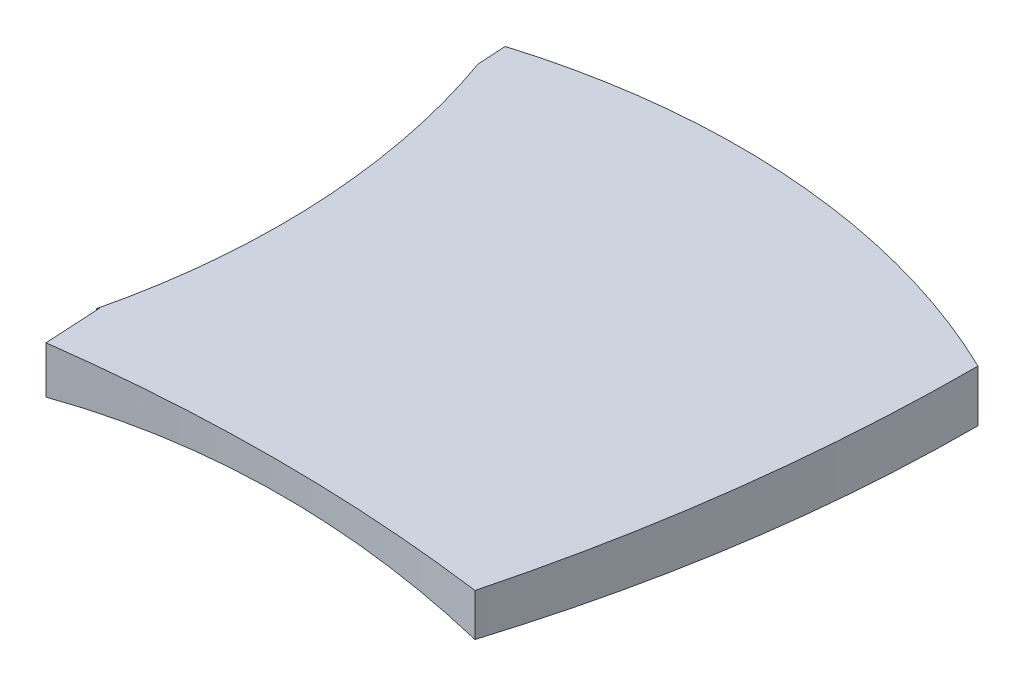
from build123d import *

# Parameters (mm, degrees)
BOSS_EXTRUDE1_DEPTH     = 15
CUT_EXTRUDE2_DEPTH      = 58
CUT_EXTRUDE2_DEPTH_BACK = 63


with BuildPart() as part:
    # Sketch1 → Boss-Extrude1 (new body)
    with BuildSketch(Plane(origin=(0, 0, 0), x_dir=(1, 0, 0), z_dir=(0, 1, 0))):
        with BuildLine():
            Line((-40, -45), (-40.554700196, -35.015396468))
            Line((-40.554700196, -35.015396468), (-40.751707535, -35.387312812))
            ThreePointArc((-40.751707535, -35.387312812), (-37.497275944, 0.081671518), (-44.445299804, 35.015396468))
            Line((-44.445299804, 35.015396468), (-44.722649902, 40.007698234))
            ThreePointArc((-44.722649902, 40.007698234), (0.805300702, 44.940375619), (45, 32.94228634))
            ThreePointArc((45, 32.94228634), (42.479652573, -6.346996403), (35, -45))
            ThreePointArc((35, -45), (-2.5, -42.500708249), (-40, -45))
        make_face()
    extrude(amount=BOSS_EXTRUDE1_DEPTH)

    # Sketch3 → Cut-Extrude2 (cut, two sides)
    with BuildSketch(Plane.XY) as cut_extrude2_sk:
        with BuildLine():
            Line((-49.722649902, 5), (-49.722649902, -2.927919572))
            Line((-49.722649902, -2.927919572), (50, -2.927919572))
            Line((50, -2.927919572), (50, 5))
            ThreePointArc((50, 5), (0.138675049, 10.0002316), (-49.722649902, 5))
        make_face()
    extrude(amount=CUT_EXTRUDE2_DEPTH, mode=Mode.SUBTRACT)
    extrude(cut_extrude2_sk.sketch, amount=-CUT_EXTRUDE2_DEPTH_BACK, mode=Mode.SUBTRACT)


solid = part.part
